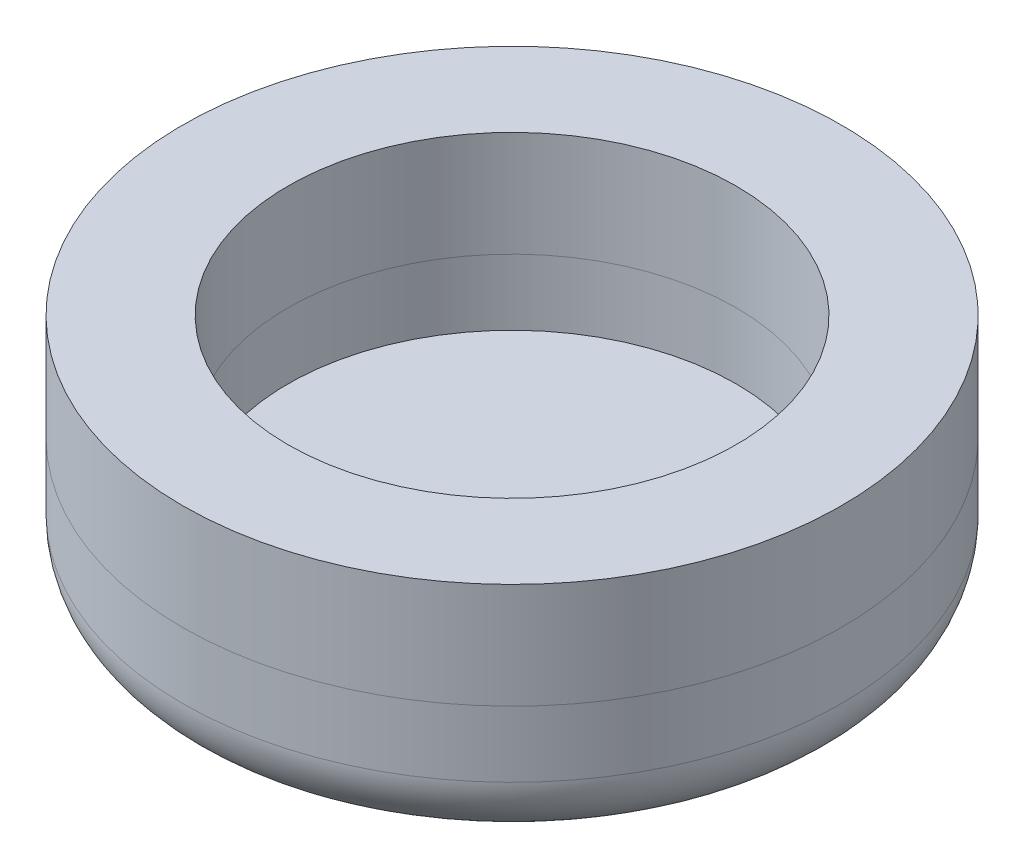
from build123d import *

# Parameters (mm, degrees)
SKETCH1_R           = 6.35
BOSS_EXTRUDE1_DEPTH = 2.54
FILLET2_R           = 1.27
SKETCH2_R           = 3.429
CUT_EXTRUDE2_DEPTH  = 1.27
SKETCH3_R           = 6.35
SKETCH3_R_2         = 3.429
BOSS_EXTRUDE2_DEPTH = 2.032
SKETCH4_R           = 3.96875
CUT_EXTRUDE3_DEPTH  = 3.302
SKETCH5_R           = 4.318
CUT_EXTRUDE4_DEPTH  = 3.302


with BuildPart() as part:
    # Sketch1 → Boss-Extrude1 (new body)
    with BuildSketch(Plane(origin=(0, 0, 0), x_dir=(1, 0, 0), z_dir=(0, 1, 0))):
        Circle(SKETCH1_R)
    extrude(amount=BOSS_EXTRUDE1_DEPTH)

    # Fillet2
    fillet2_edges = [part.edges().sort_by_distance(p)[0] for p in [
        (-6.35, 0, 0),
    ]]
    fillet(fillet2_edges, radius=FILLET2_R)

    # Sketch2 → Cut-Extrude2 (cut)
    with BuildSketch(Plane(origin=(0, 2.54, 0), x_dir=(1, 0, 0), z_dir=(0, 1, 0))):
        Circle(SKETCH2_R)
    extrude(amount=-CUT_EXTRUDE2_DEPTH, mode=Mode.SUBTRACT)


with BuildPart() as body_2:
    # Sketch3 → Boss-Extrude2 (new body)
    with BuildSketch(Plane(origin=(0, 2.54, 0), x_dir=(1, 0, 0), z_dir=(0, 1, 0))):
        Circle(SKETCH3_R)
        Circle(SKETCH3_R_2, mode=Mode.SUBTRACT)
    extrude(amount=BOSS_EXTRUDE2_DEPTH)


with BuildPart() as cut_extrude3_tool:
    # Sketch4 → Cut-Extrude3 (new body)
    with BuildSketch(Plane(origin=(0, 1.27, 0), x_dir=(1, 0, 0), z_dir=(0, 1, 0))):
        Circle(SKETCH4_R)
    extrude(amount=CUT_EXTRUDE3_DEPTH)


with BuildPart() as part_1:
    add(part.part)

    # Cut-Extrude3: cut by cut_extrude3_tool
    add(cut_extrude3_tool.part, mode=Mode.SUBTRACT)


with BuildPart() as body_2_1:
    add(body_2.part)

    # Cut-Extrude3: cut by cut_extrude3_tool
    add(cut_extrude3_tool.part, mode=Mode.SUBTRACT)


with BuildPart() as cut_extrude4_tool:
    # Sketch5 → Cut-Extrude4 (new body)
    with BuildSketch(Plane(origin=(0, 4.572, 0), x_dir=(1, 0, 0), z_dir=(0, 1, 0))):
        Circle(SKETCH5_R)
    extrude(amount=-CUT_EXTRUDE4_DEPTH)


with BuildPart() as part_2:
    add(part_1.part)

    # Cut-Extrude4: cut by cut_extrude4_tool
    add(cut_extrude4_tool.part, mode=Mode.SUBTRACT)


with BuildPart() as body_2_2:
    add(body_2_1.part)

    # Cut-Extrude4: cut by cut_extrude4_tool
    add(cut_extrude4_tool.part, mode=Mode.SUBTRACT)


solid = Compound([part_2.part, body_2_2.part])
